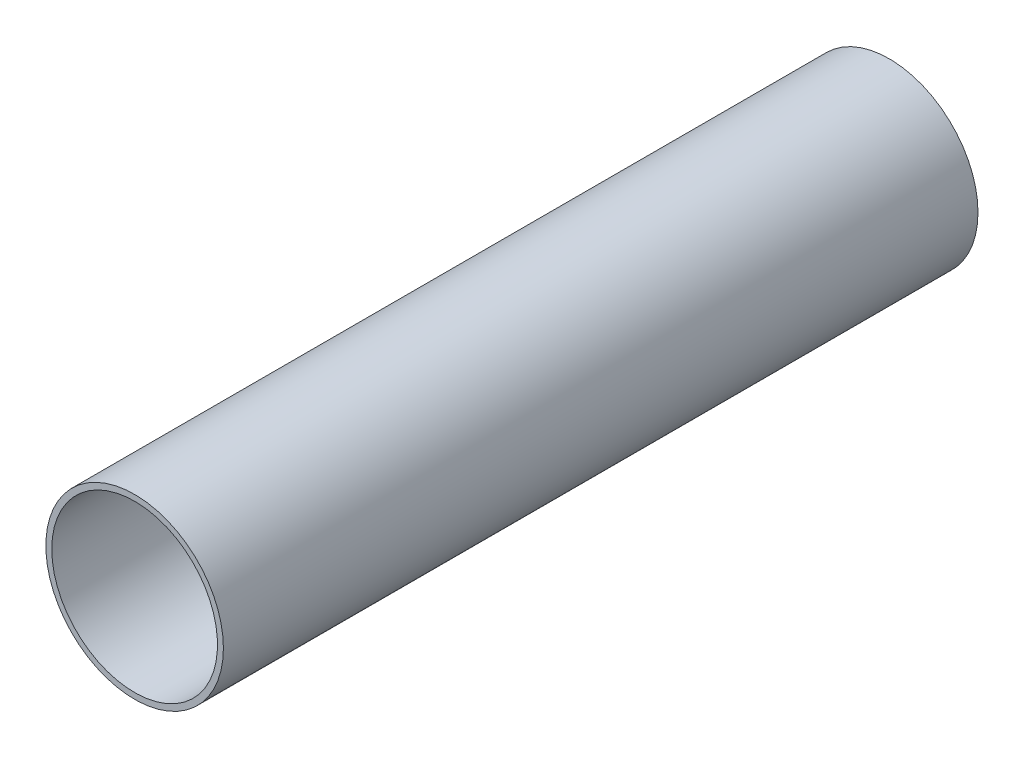
from build123d import *

# Parameters (mm, degrees)
SKETCH1_R           = 50.8
BOSS_EXTRUDE1_DEPTH = 431.8
SKETCH2_R           = 47.418840819
CUT_EXTRUDE1_DEPTH  = 431.8


with BuildPart() as part:
    # Sketch1 → Boss-Extrude1 (new body)
    with BuildSketch(Plane.XY):
        with Locations((-13.886816657, 18.265542629)):
            Circle(SKETCH1_R)
    extrude(amount=BOSS_EXTRUDE1_DEPTH)

    # Sketch2 → Cut-Extrude1 (cut)
    with BuildSketch(Plane(origin=(0, 0, 0), x_dir=(-1, 0, 0), z_dir=(0, 0, -1))):
        with Locations((13.886816657, 18.265542629)):
            Circle(SKETCH2_R)
    extrude(amount=-CUT_EXTRUDE1_DEPTH, mode=Mode.SUBTRACT)


solid = part.part
